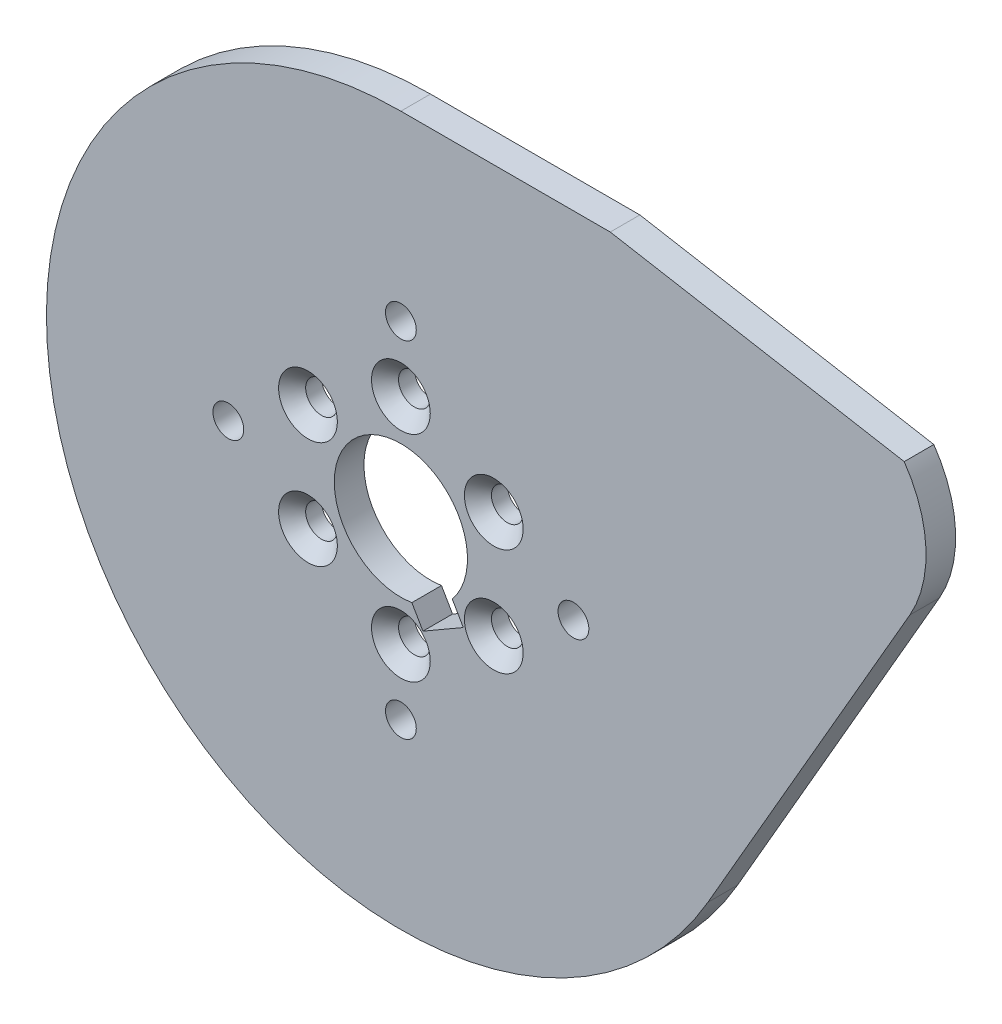
from build123d import *

# Parameters (mm, degrees)
BOSS_EXTRUDE1_DEPTH                             = 3.175
CUT_EXTRUDE1_DEPTH                              = 4.175
SKETCH3_W                                       = 7.1374
SKETCH3_H                                       = 3.175
F_3_3_3_3_DIAMETER_HOLE1_D                      = 3.3
F_3_3_3_3_DIAMETER_HOLE1_DEPTH                  = 3.175
CSK_FOR_M3_FLAT_HEAD_MACHINE_SCREW1_D           = 3.4
CSK_FOR_M3_FLAT_HEAD_MACHINE_SCREW1_DEPTH       = 3.175
CSK_FOR_M3_FLAT_HEAD_MACHINE_SCREW1_CSINK_D     = 6.3
CSK_FOR_M3_FLAT_HEAD_MACHINE_SCREW1_CSINK_ANGLE = 90


with BuildPart() as part:
    # Sketch1 → Boss-Extrude1 (new body)
    with BuildSketch(Plane.XY.offset(3.175)):
        with BuildLine():
            Line((32.908965344, -19), (54.559600438, 18.5))
            ThreePointArc((54.559600438, 18.5), (56.289246799, 25.558984429), (53.959502015, 32.443258315))
            Line((53.959502015, 32.443258315), (22.445653919, 38))
            Line((22.445653919, 38), (0, 38))
            ThreePointArc((0, 38), (-32.908965344, -19), (32.908965344, -19))
        make_face()
    extrude(amount=-BOSS_EXTRUDE1_DEPTH)

    # Sketch2 → Cut-Extrude1 (cut, through all)
    with BuildSketch(Plane(origin=(0, 0, 0), x_dir=(-1, 0, 0), z_dir=(0, 0, -1))):
        with BuildLine():
            Line((-5.507685189, -4.539590579), (-6.694313457, -6.59489103))
            Line((-6.694313457, -6.59489103), (-2.364186438, -9.09489103))
            Line((-2.364186438, -9.09489103), (-1.17755817, -7.039590579))
            ThreePointArc((-1.17755817, -7.039590579), (-3.5687, -6.181169717), (-5.507685189, -4.539590579))
        make_face()
    extrude(amount=-CUT_EXTRUDE1_DEPTH, mode=Mode.SUBTRACT)

    # Sketch3 → Cut-Revolve1 (revolve, cut)
    with BuildSketch(Plane.XZ):
        with Locations((3.5687, 1.5875)):
            Rectangle(SKETCH3_W, SKETCH3_H)
    revolve(axis=Axis((0, 0, 3.175), (0, 0, -1)), mode=Mode.SUBTRACT)

    # Ø3.3 (3.3) Diameter Hole1
    with Locations(Plane.XY.offset(3.175)):
        with Locations((18.5, 0), (0, -18.5), (-18.5, 0), (0, 18.5)):
            Hole(F_3_3_3_3_DIAMETER_HOLE1_D / 2, depth=F_3_3_3_3_DIAMETER_HOLE1_DEPTH)

    # CSK for M3 Flat Head Machine Screw1
    with Locations(Plane.XY.offset(3.175)):
        with Locations((-9.959292144, 5.75), (-9.959292144, -5.75), (0, -11.5), (9.959292144, -5.75), (9.959292144, 5.75), (0, 11.5)):
            CounterSinkHole(CSK_FOR_M3_FLAT_HEAD_MACHINE_SCREW1_D / 2, CSK_FOR_M3_FLAT_HEAD_MACHINE_SCREW1_CSINK_D / 2, depth=CSK_FOR_M3_FLAT_HEAD_MACHINE_SCREW1_DEPTH, counter_sink_angle=CSK_FOR_M3_FLAT_HEAD_MACHINE_SCREW1_CSINK_ANGLE)


solid = part.part
